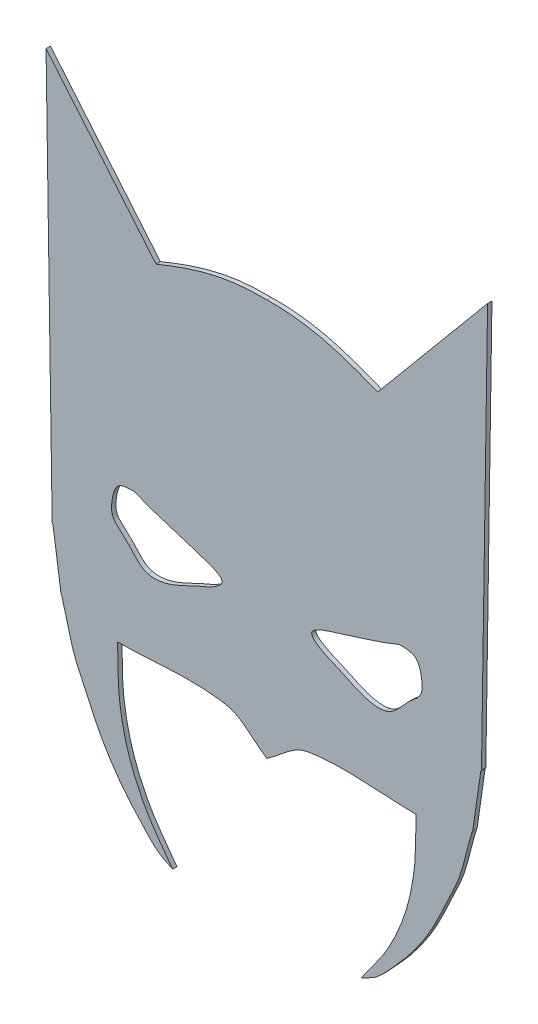
from build123d import *

# Parameters (mm, degrees)
BOSS_EXTRUDE1_DEPTH = 5


with BuildPart() as part:
    # Sketch1 → Boss-Extrude1 (new body)
    with BuildSketch(Plane.XY):
        with BuildLine():
            Line((486, 734), (612, 885))
            Line((612, 885), (605, 418))
            add(Edge.make_bspline(
                [(605, 418), (604.666666667, 417.333333333), (604.113336733, 416.736688768), (604, 416), (600.774380017, 395.033470108), (598.225619983, 373.966529892), (595, 353), (594.886663267, 352.263311232), (594.21919865, 351.712395612), (594, 351), (587.333333333, 329.333333333), (584.008588829, 306.340035362), (574, 286), (563.995740146, 265.668762231), (555.631382568, 244.44621773), (544, 225), (534.212539923, 208.636590184), (522.74531853, 193.181410759), (510, 179), (485.265923604, 151.478985419), (485.895929909, 152.447964954), (467, 143)],
                knots=[0, 0, 0, 0, 1, 1, 1, 2, 2, 2, 3, 3, 3, 4, 4, 4, 5, 5, 5, 6, 6, 6, 7, 7, 7, 7], degree=3))
            add(Edge.make_bspline(
                [(467, 143), (477.333333333, 158), (489.094886435, 172.110483639), (498, 188), (506.174286948, 202.585492397), (512.916474156, 218.071619023), (518, 234), (522.969090988, 249.569818428), (526.108691388, 265.766267748), (528, 282), (530.122974634, 300.222198941), (529.333333333, 318.666666667), (530, 337)],
                knots=[0, 0, 0, 0, 1, 1, 1, 2, 2, 2, 3, 3, 3, 4, 4, 4, 4], degree=3))
            add(Edge.make_bspline(
                [(530, 337), (488.666666667, 337), (446.711557019, 344.142378424), (406, 337), (387.69345497, 333.788325433), (374.666666667, 317), (359, 307)],
                knots=[0, 0, 0, 0, 1, 1, 1, 2, 2, 2, 2], degree=3))
            add(Edge.make_bspline(
                [(188, 337), (229.333333333, 337), (271.288442981, 344.142378424), (312, 337), (330.30654503, 333.788325433), (343.333333333, 317), (359, 307)],
                knots=[0, 0, 0, 0, 1, 1, 1, 2, 2, 2, 2], degree=3))
            add(Edge.make_bspline(
                [(251, 143), (240.666666667, 158), (228.905113565, 172.110483639), (220, 188), (211.825713052, 202.585492397), (205.083525844, 218.071619023), (200, 234), (195.030909012, 249.569818428), (191.891308612, 265.766267748), (190, 282), (187.877025366, 300.222198941), (188.666666667, 318.666666667), (188, 337)],
                knots=[0, 0, 0, 0, 1, 1, 1, 2, 2, 2, 3, 3, 3, 4, 4, 4, 4], degree=3))
            add(Edge.make_bspline(
                [(113, 418), (113.333333333, 417.333333333), (113.886663267, 416.736688768), (114, 416), (117.225619983, 395.033470108), (119.774380017, 373.966529892), (123, 353), (123.113336733, 352.263311232), (123.78080135, 351.712395612), (124, 351), (130.666666667, 329.333333333), (133.991411171, 306.340035362), (144, 286), (154.004259854, 265.668762231), (162.368617432, 244.44621773), (174, 225), (183.787460077, 208.636590184), (195.25468147, 193.181410759), (208, 179), (232.734076396, 151.478985419), (232.104070091, 152.447964954), (251, 143)],
                knots=[0, 0, 0, 0, 1, 1, 1, 2, 2, 2, 3, 3, 3, 4, 4, 4, 5, 5, 5, 6, 6, 6, 7, 7, 7, 7], degree=3))
            Line((113, 418), (106, 885))
            Line((106, 885), (232, 734))
            add(Edge.make_bspline(
                [(359, 762.027511399), (311.942070825, 763.23255689), (274.812940158, 751.51438461), (232, 734)],
                knots=[2.0070232, 2.0070232, 2.0070232, 2.0070232, 3, 3, 3, 3], degree=3))
            add(Edge.make_bspline(
                [(359, 762.027511399), (406.057929175, 763.23255689), (443.187059842, 751.51438461), (486, 734)],
                knots=[2.0070232, 2.0070232, 2.0070232, 2.0070232, 3, 3, 3, 3], degree=3))
        make_face()
        with BuildLine():
            add(Edge.make_bspline(
                [(495, 422), (476.43481401, 417.780639548), (455.524025938, 430.564188328), (439, 438), (437.242980698, 438.790658686), (400.4192653, 452.013760929), (413, 461), (416.639126714, 463.599376225), (420.781110006, 465.516434288), (425, 467), (453.539507996, 477.035870943), (483.193436371, 484.082901302), (511, 496)],
                knots=[5, 5, 5, 5, 6, 6, 6, 7, 7, 7, 8, 8, 8, 9, 9, 9, 9], degree=3))
            add(Edge.make_bspline(
                [(511, 496), (519.575175849, 495.387487439), (528.910102875, 496.543093292), (533, 487), (534.370879406, 483.801281387), (535.427874728, 480.432751634), (536, 477), (537.241500172, 469.550998965), (538.289177454, 461.347012944), (533, 455), (529.526184336, 450.831421204), (524.929370489, 447.742257608), (521, 444), (513.529162998, 436.884917141), (505.781297438, 424.450294872), (495, 422)],
                knots=[0, 0, 0, 0, 1, 1, 1, 2, 2, 2, 3, 3, 3, 4, 4, 4, 5, 5, 5, 5], degree=3))
        make_face(mode=Mode.SUBTRACT)
        with BuildLine():
            add(Edge.make_bspline(
                [(207, 496), (198.424824151, 495.387487439), (189.089897125, 496.543093292), (185, 487), (183.629120594, 483.801281387), (182.572125272, 480.432751634), (182, 477), (180.758499828, 469.550998965), (179.710822546, 461.347012944), (185, 455), (188.473815664, 450.831421204), (193.070629511, 447.742257608), (197, 444), (204.470837002, 436.884917141), (212.218702562, 424.450294872), (223, 422)],
                knots=[0, 0, 0, 0, 1, 1, 1, 2, 2, 2, 3, 3, 3, 4, 4, 4, 5, 5, 5, 5], degree=3))
            add(Edge.make_bspline(
                [(223, 422), (241.56518599, 417.780639548), (262.475974062, 430.564188328), (279, 438), (280.757019302, 438.790658686), (317.5807347, 452.013760929), (305, 461), (301.360873286, 463.599376225), (297.218889994, 465.516434288), (293, 467), (264.460492004, 477.035870943), (234.806563629, 484.082901302), (207, 496)],
                knots=[5, 5, 5, 5, 6, 6, 6, 7, 7, 7, 8, 8, 8, 9, 9, 9, 9], degree=3))
        make_face(mode=Mode.SUBTRACT)
    extrude(amount=BOSS_EXTRUDE1_DEPTH)


solid = part.part
